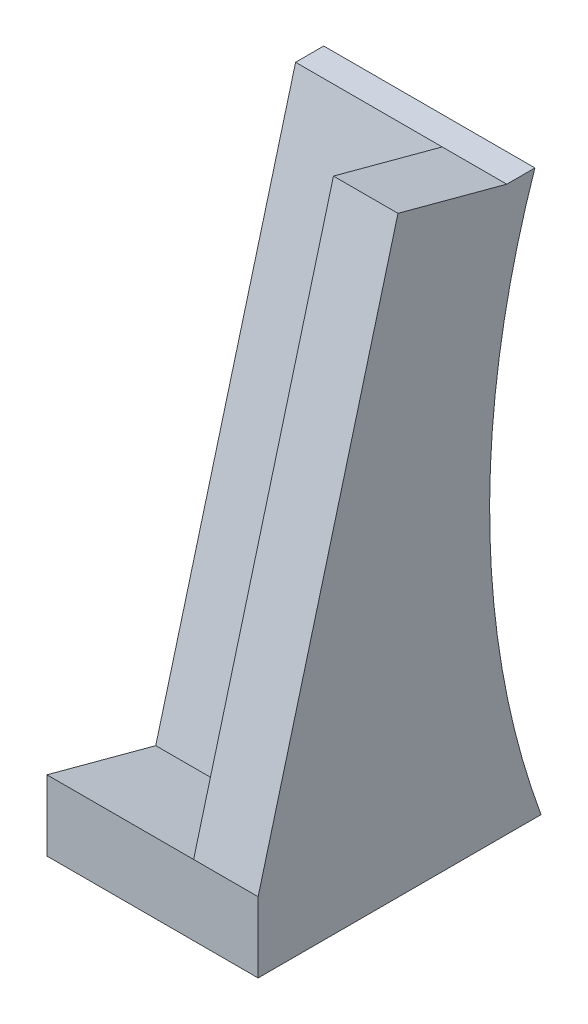
from build123d import *

# Parameters (mm, degrees)
BOSS_EXTRUDE1_DEPTH = 38.1
SKETCH2_W           = 11.640498825
SKETCH2_H           = 97.480780029
BOSS_EXTRUDE2_DEPTH = 20.32


with BuildPart() as part:
    # Sketch1 → Boss-Extrude1 (new body)
    with BuildSketch(Plane(origin=(0, 0, 0), x_dir=(0, 0, -1), z_dir=(1, 0, 0))):
        with BuildLine():
            Line((0, 0), (51.044233981, 0))
            ThreePointArc((51.044233981, 0), (41.774414057, 50.705050847), (49.937495193, 101.6))
            Line((49.937495193, 101.6), (44.857495193, 101.6))
            Line((44.857495193, 101.6), (19.62761279, 7.440797004))
            Line((19.62761279, 7.440797004), (0, 12.7))
            Line((0, 12.7), (0, 0))
        make_face()
    extrude(amount=BOSS_EXTRUDE1_DEPTH)

    # Sketch2 → Boss-Extrude2 (add)
    with BuildSketch(Plane(origin=(0, -4.408464311, -16.45261279), x_dir=(1, 0, 0), z_dir=(0, 0.258819045, 0.965925826))):
        with Locations((32.279750588, 61.007648009)):
            Rectangle(SKETCH2_W, SKETCH2_H)
    extrude(amount=BOSS_EXTRUDE2_DEPTH)


solid = part.part
